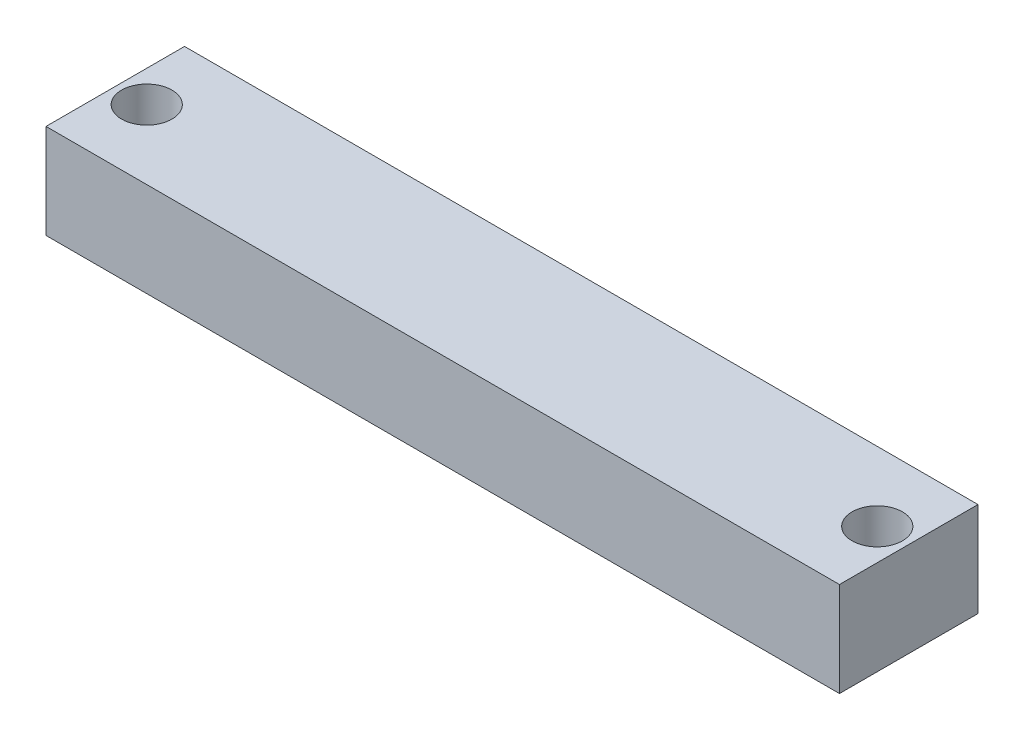
from build123d import *

# Parameters (mm, degrees)
SKETCH5_W           = 126
SKETCH5_H           = 22
BOSS_EXTRUDE5_DEPTH = 15
SKETCH6_R           = 1.200912212
CUT_EXTRUDE1_DEPTH  = 10
SKETCH7_R           = 4
CUT_EXTRUDE2_DEPTH  = 16


with BuildPart() as part:
    # Sketch5 → Boss-Extrude5 (new body)
    with BuildSketch(Plane(origin=(0, 0, 0), x_dir=(1, 0, 0), z_dir=(0, 1, 0))):
        with Locations((63, 11)):
            Rectangle(SKETCH5_W, SKETCH5_H)
    extrude(amount=BOSS_EXTRUDE5_DEPTH)

    # Sketch6 → Cut-Extrude1 (cut)
    with BuildSketch(Plane.ZY):
        with Locations((-11.222048747, 2.781464134)):
            Circle(SKETCH6_R)
    extrude(amount=-CUT_EXTRUDE1_DEPTH, mode=Mode.SUBTRACT)

    # Sketch7 → Cut-Extrude2 (cut, through all)
    with BuildSketch(Plane(origin=(0, 15, 0), x_dir=(1, 0, 0), z_dir=(0, 1, 0))):
        with Locations((5, 11)):
            Circle(SKETCH7_R)
        with Locations((121, 11)):
            Circle(SKETCH7_R)
    extrude(amount=-CUT_EXTRUDE2_DEPTH, mode=Mode.SUBTRACT)


solid = part.part
